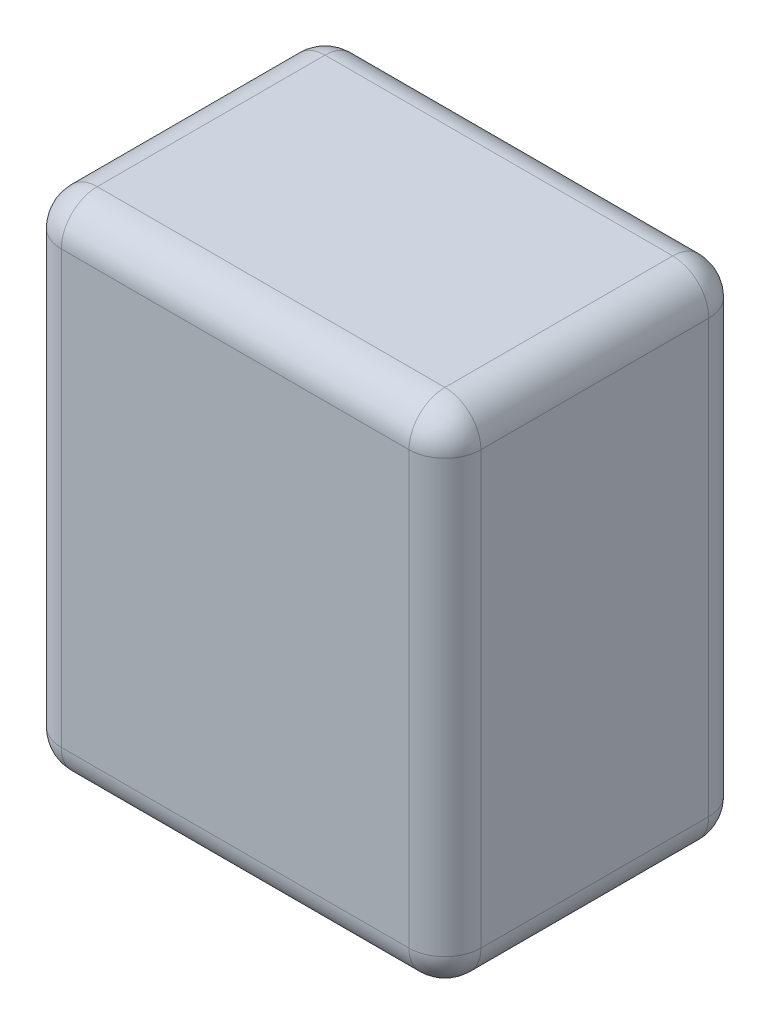
from build123d import *

# Parameters (mm, degrees)
SKETCH1_W           = 35
SKETCH1_H           = 25
BOSS_EXTRUDE1_DEPTH = 42
FILLET1_R           = 3


with BuildPart() as part:
    # Sketch1 → Boss-Extrude1 (new body)
    with BuildSketch(Plane(origin=(0, 0, 0), x_dir=(1, 0, 0), z_dir=(0, 1, 0))):
        Rectangle(SKETCH1_W, SKETCH1_H)
    extrude(amount=BOSS_EXTRUDE1_DEPTH)

    # Fillet1
    fillet1_edges = [part.edges().sort_by_distance(p)[0] for p in [
        (-17.5, 42, 0),
        (0, 42, 12.5),
        (17.5, 42, 0),
        (0, 0, 12.5),
        (-17.5, 0, 0),
        (0, 0, -12.5),
        (17.5, 0, 0),
        (17.5, 21, 12.5),
        (-17.5, 21, 12.5),
        (-17.5, 21, -12.5),
        (17.5, 21, -12.5),
        (0, 42, -12.5),
    ]]
    fillet(fillet1_edges, radius=FILLET1_R)


solid = part.part
